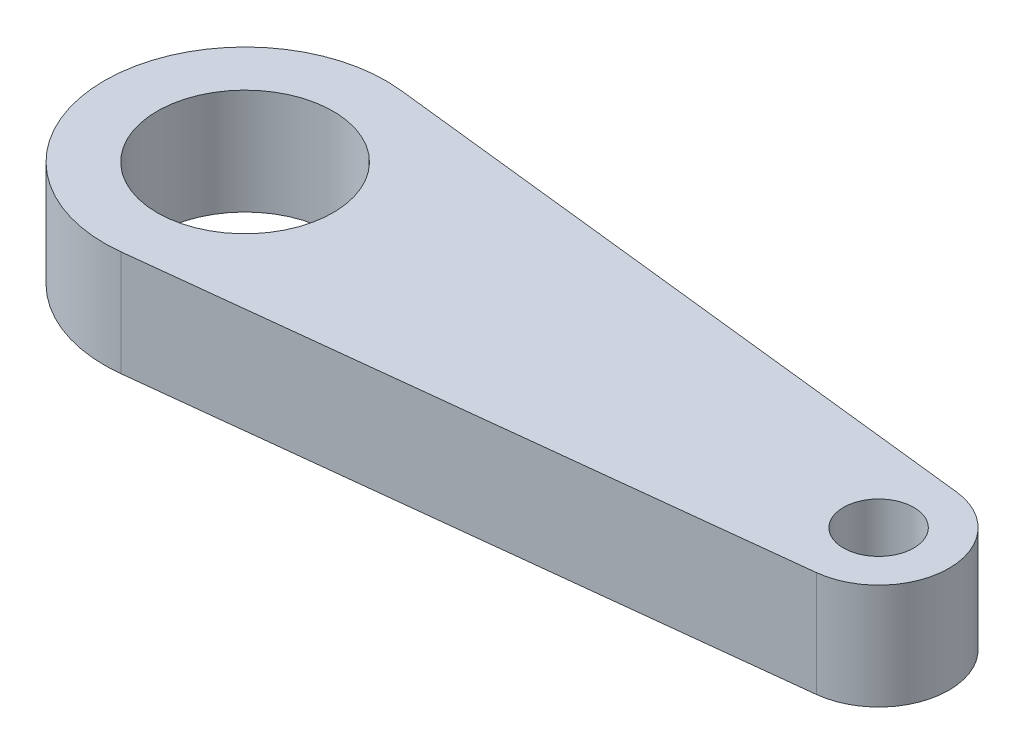
from build123d import *

# Parameters (mm, degrees)
SKETCH_1_R      = 2.5
SKETCH_1_R_2    = 1
EXTRUDE_1_DEPTH = 3


with BuildPart() as part:
    # 草图1 → 凸台-拉伸1 (new body)
    with BuildSketch(Plane(origin=(0, 0, 0), x_dir=(1, 0, 0), z_dir=(0, 1, 0))):
        with BuildLine():
            Line((18.222222222, 1.98761598), (0.444444444, 3.97523196))
            ThreePointArc((0.444444444, 3.97523196), (-4, 0), (0.444444444, -3.97523196))
            Line((0.444444444, -3.97523196), (18.222222222, -1.98761598))
            ThreePointArc((18.222222222, -1.98761598), (20, 0), (18.222222222, 1.98761598))
        make_face()
        Circle(SKETCH_1_R, mode=Mode.SUBTRACT)
        with Locations((18, 0)):
            Circle(SKETCH_1_R_2, mode=Mode.SUBTRACT)
    extrude(amount=EXTRUDE_1_DEPTH)


solid = part.part
